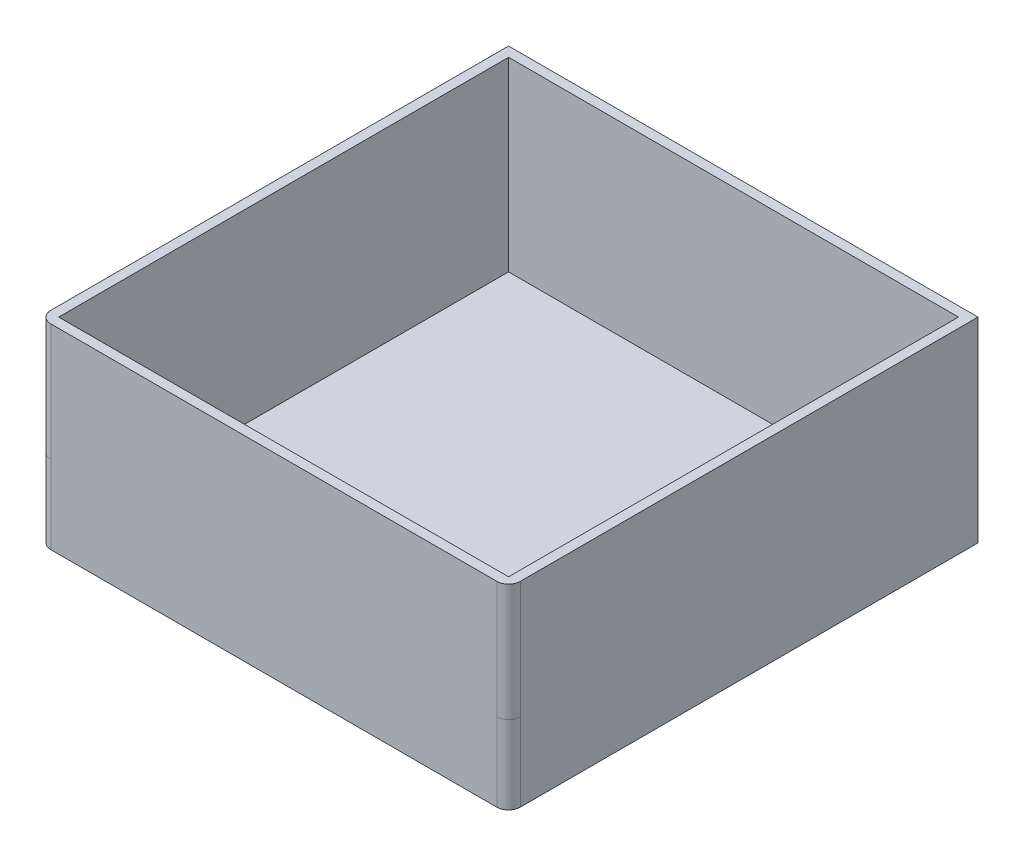
from build123d import *

# Parameters (mm, degrees)
BOSS_EXTRU_1_DEPTH      = 120
CONG_1_R                = 3
ESQUISSE3_W             = 57.5
ESQUISSE3_H             = 57.5
ENL_V_MAT_EXTRU_1_DEPTH = 17.5
ESQUISSE4_W             = 120
ESQUISSE4_H             = 120
ESQUISSE4_W_2           = 115
ESQUISSE4_H_2           = 115
BOSS_EXTRU_2_DEPTH      = 30
CONG_2_R                = 3


with BuildPart() as part:
    # Esquisse2 → Boss.-Extru.1 (new body)
    with BuildSketch(Plane(origin=(0, 0, 0), x_dir=(0, 0, -1), z_dir=(1, 0, 0))):
        Polygon((0, 20), (0, 0), (118.743991381, 0), (120, 0), (120, 20), align=None)
    extrude(amount=BOSS_EXTRU_1_DEPTH)

    # Congé1
    cong_1_edges = [part.edges().sort_by_distance(p)[0] for p in [
        (120, 10, 0),
        (0, 10, 0),
    ]]
    fillet(cong_1_edges, radius=CONG_1_R)

    # Esquisse3 → Enlèv. mat.-Extru.1 (cut)
    with BuildSketch(Plane(origin=(0, 20, 0), x_dir=(1, 0, 0), z_dir=(0, 1, 0))):
        with Locations((31.25, 88.75)):
            Rectangle(ESQUISSE3_W, ESQUISSE3_H)
        with Locations((88.75, 88.75)):
            Rectangle(ESQUISSE3_W, ESQUISSE3_H)
        with Locations((31.25, 31.25)):
            Rectangle(ESQUISSE3_W, ESQUISSE3_H)
        with Locations((88.75, 31.25)):
            Rectangle(ESQUISSE3_W, ESQUISSE3_H)
    extrude(amount=-ENL_V_MAT_EXTRU_1_DEPTH, mode=Mode.SUBTRACT)

    # Esquisse4 → Boss.-Extru.2 (add)
    with BuildSketch(Plane(origin=(0, 20, 0), x_dir=(1, 0, 0), z_dir=(0, 1, 0))):
        with Locations((60, 60)):
            Rectangle(ESQUISSE4_W, ESQUISSE4_H)
        with Locations((60, 60)):
            Rectangle(ESQUISSE4_W_2, ESQUISSE4_H_2, mode=Mode.SUBTRACT)
    extrude(amount=BOSS_EXTRU_2_DEPTH)

    # Congé2
    cong_2_edges = [part.edges().sort_by_distance(p)[0] for p in [
        (120, 35, 0),
        (0, 35, 0),
    ]]
    fillet(cong_2_edges, radius=CONG_2_R)


solid = part.part
